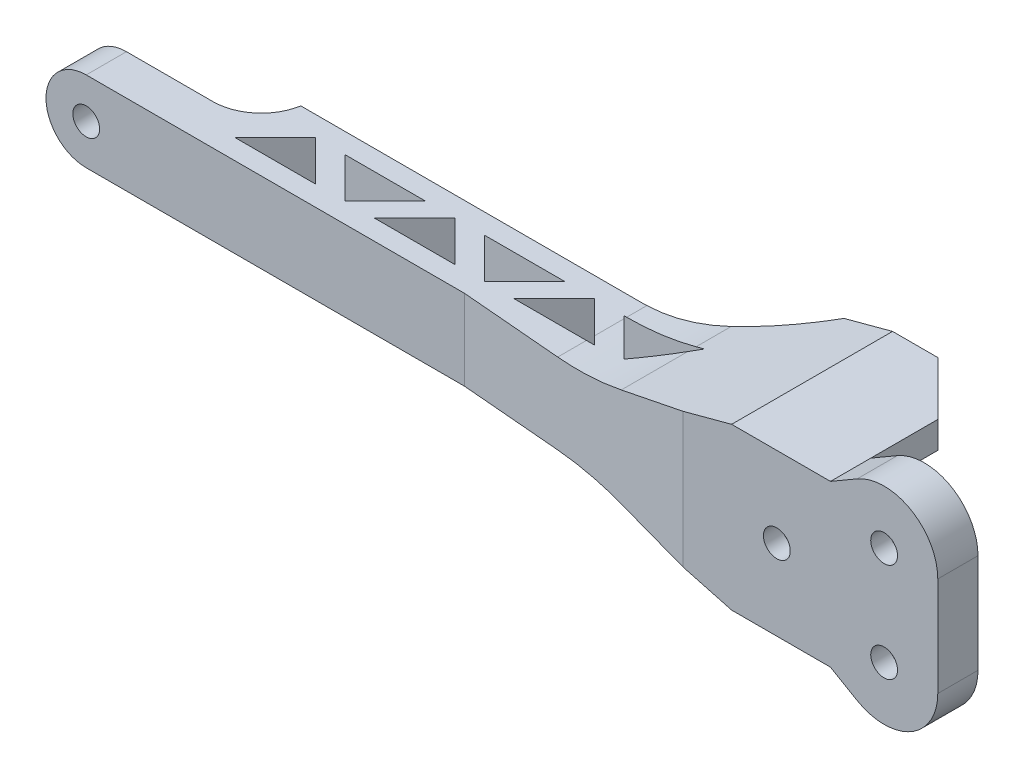
from build123d import *

# Parameters (mm, degrees)
BOSS_EXTRUDE1_DEPTH     = 77
SKETCH2_W               = 126.439286786
SKETCH2_H               = 23.5
CUT_EXTRUDE1_DEPTH      = 23.5
CUT_EXTRUDE1_DEPTH_BACK = 38.5
CUT_EXTRUDE2_DEPTH      = 23.5000001
CUT_EXTRUDE2_DEPTH_BACK = 22.5
SKETCH3_R               = 5
CUT_EXTRUDE3_DEPTH      = 46.0000001
CUT_EXTRUDE3_DEPTH_BACK = 16
SKETCH4_R               = 7.5
SKETCH4_R_2             = 5
CUT_EXTRUDE4_DEPTH      = 8


with BuildPart() as part:
    # Sketch1 → Boss-Extrude1 (new body)
    with BuildSketch(Plane(origin=(0, 0, 0), x_dir=(1, 0, 0), z_dir=(0, 1, 0))):
        with BuildLine():
            Line((0, 0), (126.439286786, 0))
            ThreePointArc((126.439286786, 0), (155.486661882, 5.85341657), (180, 22.5))
            Line((180, 22.5), (215, 22.5))
            Line((215, 22.5), (235, 2.5))
            Line((235, 2.5), (235, -22.5))
            Line((235, -22.5), (275, -22.5))
            Line((275, -22.5), (275, -37.5))
            Line((275, -37.5), (180, -37.5))
            Line((180, -37.5), (91, -30))
            Line((91, -30), (-65, -30))
            Line((-65, -30), (-65, -15))
            Line((-65, -15), (-17.748239349, -15))
            ThreePointArc((-17.748239349, -15), (-6.129289311, -10.747727085), (0, 0))
        make_face()
        Polygon((-2, -22.5), (13, -7.5), (28, -22.5), align=None, mode=Mode.SUBTRACT)
        Polygon((50, -22.5), (65, -7.5), (80, -22.5), align=None, mode=Mode.SUBTRACT)
        Polygon((54, -7.5), (39, -22.5), (24, -7.5), align=None, mode=Mode.SUBTRACT)
        Polygon((106, -7.5), (91, -22.5), (76, -7.5), align=None, mode=Mode.SUBTRACT)
        Polygon((158, -7.5), (143, -22.5), (128, -7.5), align=None, mode=Mode.SUBTRACT)
        Polygon((102, -22.5), (117, -7.5), (132, -22.5), align=None, mode=Mode.SUBTRACT)
    extrude(amount=BOSS_EXTRUDE1_DEPTH)

    # Sketch2 → Cut-Extrude1 (cut, two sides)
    with BuildSketch(Plane(origin=(0, 0, 0), x_dir=(-1, 0, 0), z_dir=(0, 0, -1))) as cut_extrude1_sk:
        with Locations((-63.219643393, 11.75)):
            Rectangle(SKETCH2_W, SKETCH2_H)
        with BuildLine():
            Line((50, 23.5), (0, 23.5))
            Line((0, 23.5), (0, 0))
            Line((0, 0), (65, 0))
            Line((65, 0), (65, 38.5))
            ThreePointArc((65, 38.5), (60.606601718, 27.893398282), (50, 23.5))
        make_face()
        with BuildLine():
            Line((0, 77), (0, 53.5))
            Line((0, 53.5), (50, 53.5))
            ThreePointArc((50, 53.5), (60.606601718, 49.106601718), (65, 38.5))
            Line((65, 38.5), (65, 77))
            Line((65, 77), (0, 77))
        make_face()
        with Locations((-63.219643393, 65.25)):
            Rectangle(SKETCH2_W, SKETCH2_H)
        with BuildLine():
            ThreePointArc((-154.88190451, 56.907417371), (-142.052619222, 54.355513863), (-129, 53.5))
            Line((-129, 53.5), (-126.439286786, 53.5))
            Line((-126.439286786, 53.5), (-126.439286786, 77))
            Line((-126.439286786, 77), (-255, 77))
            ThreePointArc((-255, 77), (-249.789539733, 76.309352755), (-244.938938469, 74.28511038))
            Line((-244.938938469, 74.28511038), (-235, 68.5))
            Line((-235, 68.5), (-198.146011872, 68.5))
            Line((-198.146011872, 68.5), (-154.88190451, 56.907417371))
        make_face()
        with BuildLine():
            ThreePointArc((-129, 23.5), (-142.052619222, 22.644486137), (-154.88190451, 20.092582629))
            Line((-154.88190451, 20.092582629), (-198.146011872, 8.5))
            Line((-198.146011872, 8.5), (-235, 8.5))
            Line((-235, 8.5), (-244.938938469, 2.71488962))
            ThreePointArc((-244.938938469, 2.71488962), (-249.789539733, 0.690647245), (-255, 0))
            Line((-255, 0), (-126.439286786, 0))
            Line((-126.439286786, 0), (-126.439286786, 23.5))
            Line((-126.439286786, 23.5), (-129, 23.5))
        make_face()
        with BuildLine():
            Line((-275, 0), (-255, 0))
            ThreePointArc((-255, 0), (-269.142135624, 5.857864376), (-275, 20))
            Line((-275, 20), (-275, 0))
        make_face()
        with BuildLine():
            ThreePointArc((-275, 57), (-269.142135624, 71.142135624), (-255, 77))
            Line((-255, 77), (-275, 77))
            Line((-275, 77), (-275, 57))
        make_face()
    extrude(amount=CUT_EXTRUDE1_DEPTH, mode=Mode.SUBTRACT)
    extrude(cut_extrude1_sk.sketch, amount=-CUT_EXTRUDE1_DEPTH_BACK, mode=Mode.SUBTRACT)

    # Sketch2_3 → Cut-Extrude2 (cut, two sides)
    with BuildSketch(Plane(origin=(0, 0, 0), x_dir=(-1, 0, 0), z_dir=(0, 0, -1))) as cut_extrude2_sk:
        with BuildLine():
            Line((-244.938938469, 2.71488962), (-235, 8.5))
            Line((-235, 8.5), (-235, 18.5))
            Line((-235, 18.5), (-205, 18.5))
            ThreePointArc((-205, 18.5), (-194.393398282, 22.893398282), (-190, 33.5))
            Line((-190, 33.5), (-190, 43.5))
            ThreePointArc((-190, 43.5), (-194.393398282, 54.106601718), (-205, 58.5))
            Line((-205, 58.5), (-235, 58.5))
            Line((-235, 58.5), (-235, 68.5))
            Line((-235, 68.5), (-244.938938469, 74.28511038))
            ThreePointArc((-244.938938469, 74.28511038), (-237.661873939, 66.969422485), (-235, 57))
            Line((-235, 57), (-235, 20))
            ThreePointArc((-235, 20), (-237.661873939, 10.030577515), (-244.938938469, 2.71488962))
        make_face()
    extrude(amount=CUT_EXTRUDE2_DEPTH, mode=Mode.SUBTRACT)
    extrude(cut_extrude2_sk.sketch, amount=-CUT_EXTRUDE2_DEPTH_BACK, mode=Mode.SUBTRACT)

    # Sketch3 → Cut-Extrude3 (cut, two sides)
    with BuildSketch(Plane(origin=(0, 0, 22.5), x_dir=(-1, 0, 0), z_dir=(0, 0, -1))) as cut_extrude3_sk:
        with Locations((-215, 38.5)):
            Circle(SKETCH3_R)
        with Locations((-255, 20.04)):
            Circle(SKETCH3_R)
        with Locations((-255, 56.96)):
            Circle(SKETCH3_R)
        with Locations((50, 38.5)):
            Circle(SKETCH3_R)
    extrude(amount=CUT_EXTRUDE3_DEPTH, mode=Mode.SUBTRACT)
    extrude(cut_extrude3_sk.sketch, amount=-CUT_EXTRUDE3_DEPTH_BACK, mode=Mode.SUBTRACT)

    # Sketch4 → Cut-Extrude4 (cut)
    with BuildSketch(Plane(origin=(0, 0, 22.5), x_dir=(-1, 0, 0), z_dir=(0, 0, -1))):
        with Locations((-215, 38.5)):
            Circle(SKETCH4_R)
        with Locations((-215, 38.5)):
            Circle(SKETCH4_R_2, mode=Mode.SUBTRACT)
        with Locations((-255, 20.04)):
            Circle(SKETCH4_R)
        with Locations((-255, 20.04)):
            Circle(SKETCH4_R_2, mode=Mode.SUBTRACT)
        with Locations((-255, 56.96)):
            Circle(SKETCH4_R)
        with Locations((-255, 56.96)):
            Circle(SKETCH4_R_2, mode=Mode.SUBTRACT)
    extrude(amount=-CUT_EXTRUDE4_DEPTH, mode=Mode.SUBTRACT)


solid = part.part
